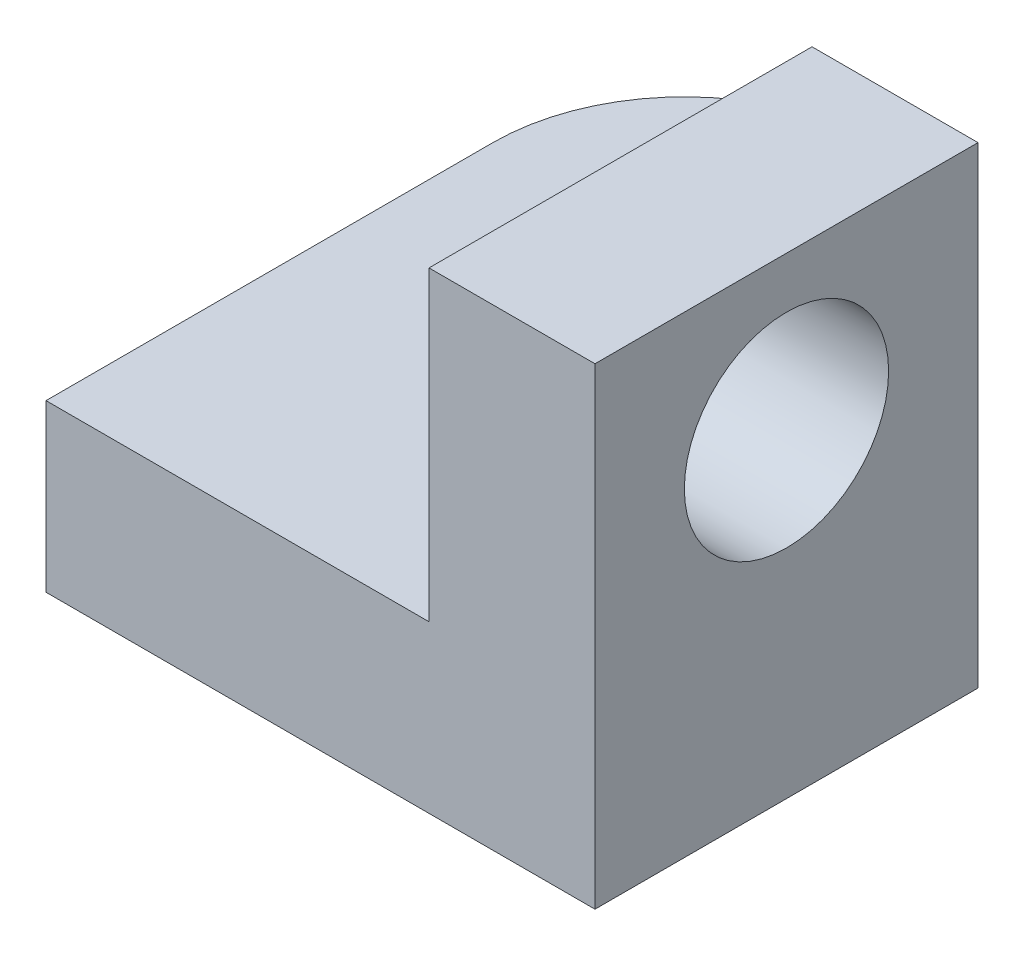
from build123d import *

# Parameters (mm, degrees)
SKETCH1_R           = 6.5
BOSS_EXTRUDE1_DEPTH = 13
BOSS_EXTRUDE2_START = 19.9
SKETCH2_W           = 30
SKETCH2_H           = 37
SKETCH2_R           = 8
BOSS_EXTRUDE2_DEPTH = 13


with BuildPart() as part:
    # Sketch1 → Boss-Extrude1 (new body)
    with BuildSketch(Plane(origin=(0, 0, 0), x_dir=(1, 0, 0), z_dir=(0, 1, 0))):
        with BuildLine():
            Line((-10.098039216, -5.637254902), (19.901960784, -5.637254902))
            Line((19.901960784, -5.637254902), (19.901960784, 29.362745098))
            ThreePointArc((19.901960784, 29.362745098), (4.901960784, 44.362745098), (-10.098039216, 29.362745098))
            Line((-10.098039216, 29.362745098), (-10.098039216, -5.637254902))
        make_face()
        with Locations((4.901960784, 29.362745098)):
            Circle(SKETCH1_R, mode=Mode.SUBTRACT)
    extrude(amount=BOSS_EXTRUDE1_DEPTH)

    # Sketch2 → Boss-Extrude2 (add)
    with BuildSketch(Plane(origin=(0, 0, 0), x_dir=(0, 0, -1), z_dir=(1, 0, 0)).offset(BOSS_EXTRUDE2_START)):
        with Locations((9.362745098, 18.5)):
            Rectangle(SKETCH2_W, SKETCH2_H)
        with Locations((9.362745098, 25)):
            Circle(SKETCH2_R, mode=Mode.SUBTRACT)
    extrude(amount=BOSS_EXTRUDE2_DEPTH)


solid = part.part
